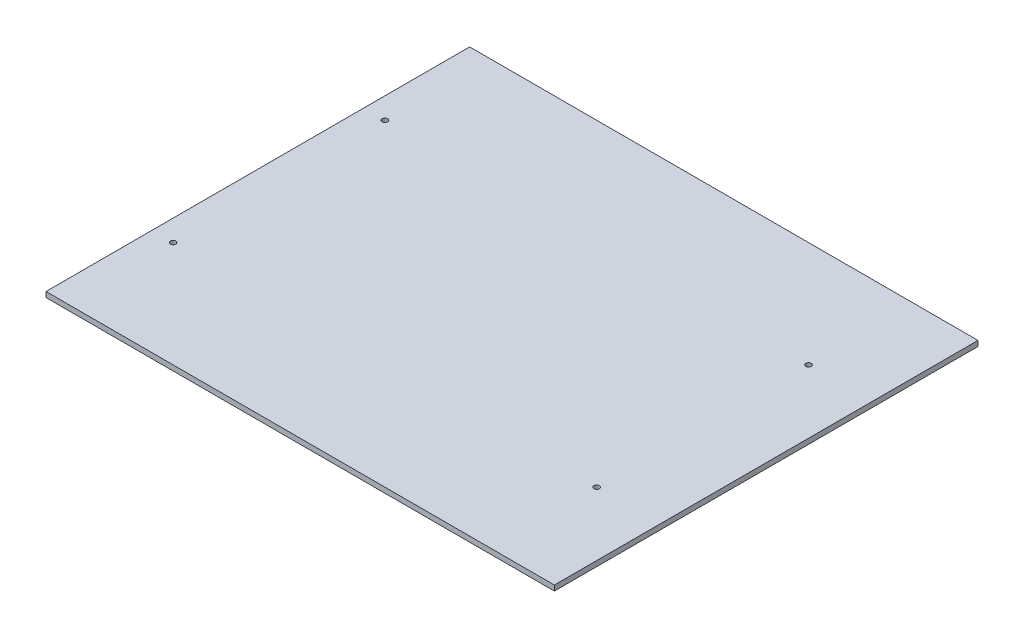
from build123d import *

# Parameters (mm, degrees)
SKETCH1_W                   = 609.6
SKETCH1_H                   = 508
BOSS_EXTRUDE1_DEPTH         = 6.35
F_1_4_CLEARANCE_HOLE1_D     = 6.5278
F_1_4_CLEARANCE_HOLE1_DEPTH = 22.352
F_1_4_CLEARANCE_HOLE1_TIP   = 1.961148974


with BuildPart() as part:
    # Sketch1 → Boss-Extrude1 (new body)
    with BuildSketch(Plane(origin=(0, 0, 0), x_dir=(1, 0, 0), z_dir=(0, 1, 0))):
        with Locations((-304.8, 254)):
            Rectangle(SKETCH1_W, SKETCH1_H)
    extrude(amount=BOSS_EXTRUDE1_DEPTH)

    # 1/4 Clearance Hole1
    with Locations(Plane(origin=(0, 6.35, 0), x_dir=(1, 0, 0), z_dir=(0, 1, 0))):
        with Locations((-76.2, 381), (-76.2, 127), (-584.2, 127), (-584.2, 381)):
            Hole(F_1_4_CLEARANCE_HOLE1_D / 2, depth=F_1_4_CLEARANCE_HOLE1_DEPTH)
            with Locations((0, 0, -(F_1_4_CLEARANCE_HOLE1_DEPTH + F_1_4_CLEARANCE_HOLE1_TIP / 2))):  # 118° drill point
                Cone(0, F_1_4_CLEARANCE_HOLE1_D / 2, F_1_4_CLEARANCE_HOLE1_TIP, mode=Mode.SUBTRACT)


solid = part.part
